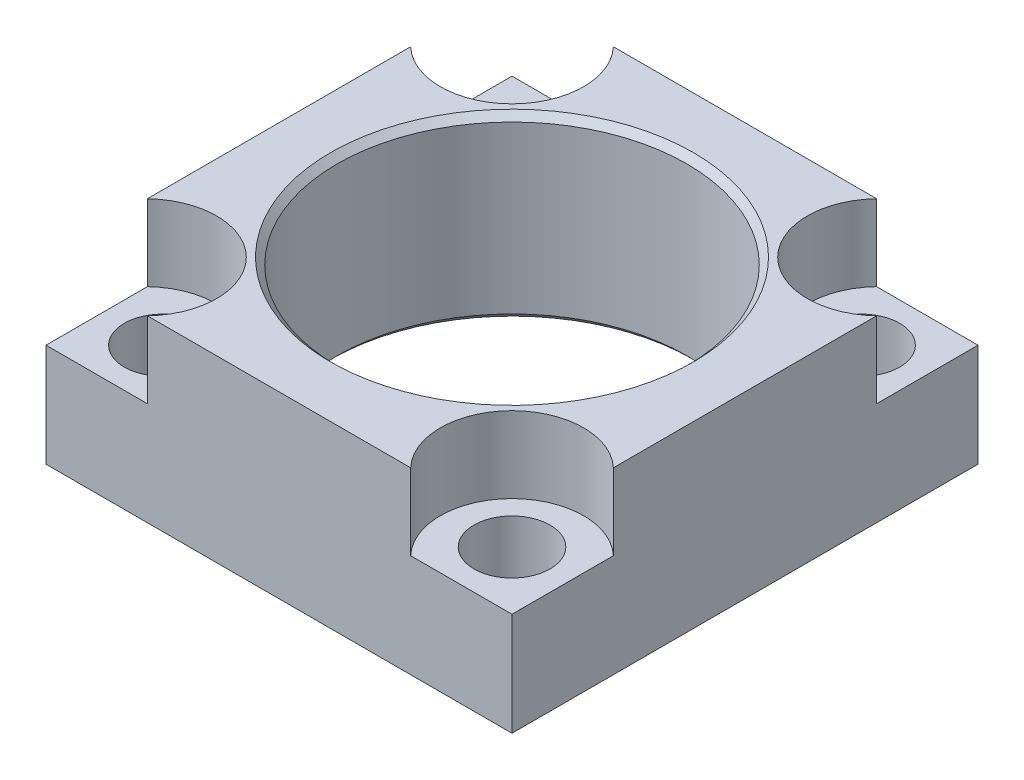
from build123d import *

# Parameters (mm, degrees)
SKETCH1_W          = 82.55
SKETCH1_H          = 82.55
SKETCH1_R          = 30.9753
EXTRUDE1_DEPTH     = 31.75
CUT_EXTRUDE1_DEPTH = 13.4874
HOLE1_D            = 13.4874
HOLE1_DEPTH        = 18.2626


with BuildPart() as part:
    # Sketch1 → Extrude1 (new body)
    with BuildSketch(Plane(origin=(0, 0, 0), x_dir=(1, 0, 0), z_dir=(0, 1, 0))):
        Rectangle(SKETCH1_W, SKETCH1_H)
        with Locations(Location((0, 0, 0), (0, 0, 270))):  # turned: the seam where the file's is
            Circle(SKETCH1_R, mode=Mode.SUBTRACT)
    extrude(amount=EXTRUDE1_DEPTH)

    # Sketch2 → Cut-Extrude1 (cut)
    with BuildSketch(Plane(origin=(0, 31.75, 0), x_dir=(1, 0, 0), z_dir=(0, 1, 0))):
        with BuildLine():
            Line((23.319621037, -41.275), (41.275, -41.275))
            Line((41.275, -41.275), (41.275, -23.319621037))
            ThreePointArc((41.275, -23.319621037), (23.531743879, -23.531743879), (23.319621037, -41.275))
        make_face()
        with BuildLine():
            Line((41.275, 41.275), (41.275, 23.319621037))
            ThreePointArc((41.275, 23.319621037), (23.531743879, 23.531743879), (23.319621037, 41.275))
            Line((23.319621037, 41.275), (41.275, 41.275))
        make_face()
        with BuildLine():
            Line((-23.319621037, 41.275), (-41.275, 41.275))
            Line((-41.275, 41.275), (-41.275, 23.319621037))
            ThreePointArc((-41.275, 23.319621037), (-23.531743879, 23.531743879), (-23.319621037, 41.275))
        make_face()
        with BuildLine():
            Line((-41.275, -41.275), (-41.275, -23.319621037))
            ThreePointArc((-41.275, -23.319621037), (-23.531743879, -23.531743879), (-23.319621037, -41.275))
            Line((-23.319621037, -41.275), (-41.275, -41.275))
        make_face()
    extrude(amount=-CUT_EXTRUDE1_DEPTH, mode=Mode.SUBTRACT)

    # Hole1
    with Locations(Plane(origin=(0, 18.2626, 0), x_dir=(-1, 0, 0), z_dir=(0, 1, 0))):
        with Locations((30.9626, 30.9626), (30.9626, -30.9626), (-30.9626, 30.9626), (-30.9626, -30.9626)):
            Hole(HOLE1_D / 2, depth=HOLE1_DEPTH)

    # Sketch5 → Cut-Revolve1 (revolve, cut)
    with BuildSketch(Plane(origin=(0, 0, 0), x_dir=(0, 0, -1), z_dir=(1, 0, 0)), mode=Mode.PRIVATE) as cut_revolve1_sk:
        Polygon((-32.131, 31.75), (-30.9753, 31.75), (-30.9753, 30.5943), align=None)
        Polygon((-30.9753, 1.1557), (-32.131, 0), (-30.9753, 0), align=None)
    revolve(cut_revolve1_sk.sketch.rotate(Axis((0, 0, 0), (0, 1, 0)), 180), axis=Axis((0, 0, 0), (0, 1, 0)), mode=Mode.SUBTRACT)  # turned: the seam where the file's is


solid = part.part
